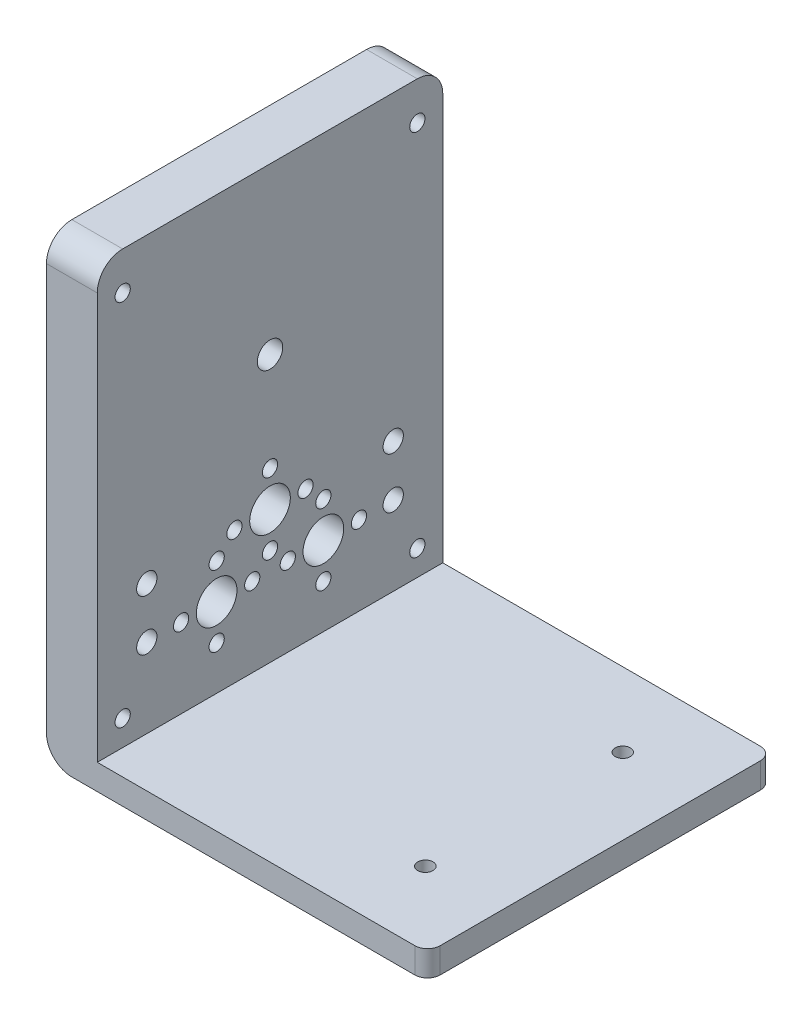
from build123d import *

# Parameters (mm, degrees)
EXTRUDE_1_DEPTH     = 68
SKETCH_2_R          = 2.5
CUT_EXTRUDE_1_DEPTH = 76
FILLET_1_R          = 5
FILLET_3_R          = 5
SKETCH_7_R          = 1.5
CUT_EXTRUDE_5_DEPTH = 10
SKETCH_8_R          = 1.5
CUT_EXTRUDE_6_DEPTH = 10
SKETCH_9_R          = 1.5
CUT_EXTRUDE_7_DEPTH = 10
FILLET_4_R          = 2.5
SKETCH_14_R         = 2
SKETCH_14_R_2       = 1.5
SKETCH_14_R_3       = 4
CUT_EXTRUDE_9_DEPTH = 76


with BuildPart() as part:
    # 草图1 → 凸台-拉伸1 (new body)
    with BuildSketch(Plane.XY):
        Polygon((-15.418994413, 41.899441341), (-15.418994413, -48.100558659), (59.581005587, -48.100558659), (59.581005587, -43.100558659), (-5.418994413, -43.100558659), (-5.418994413, 41.899441341), align=None)
    extrude(amount=EXTRUDE_1_DEPTH)

    # 草图2 → 切除-拉伸1 (cut, through all)
    with BuildSketch(Plane.ZY.offset(15.418994413)):
        with Locations((34, 9.399441341)):
            Circle(SKETCH_2_R)
    extrude(amount=-CUT_EXTRUDE_1_DEPTH, mode=Mode.SUBTRACT)

    # 圆角1
    fillet_1_edges = [part.edges().sort_by_distance(p)[0] for p in [
        (-10.418994413, 41.899441341, 68),
        (-10.418994413, 41.899441341, 0),
    ]]
    fillet(fillet_1_edges, radius=FILLET_1_R)

    # 圆角3
    fillet_3_edges = [part.edges().sort_by_distance(p)[0] for p in [
        (-15.418994413, -48.100558659, 34),
    ]]
    fillet(fillet_3_edges, radius=FILLET_3_R)

    # 草图7 → 切除-拉伸5 (cut)
    with BuildSketch(Plane.ZY.offset(15.418994413)):
        with Locations((63, 34.399441341)):
            Circle(SKETCH_7_R)
        with Locations((5, 34.399441341)):
            Circle(SKETCH_7_R)
    extrude(amount=-CUT_EXTRUDE_5_DEPTH, mode=Mode.SUBTRACT)

    # 草图8 → 切除-拉伸6 (cut)
    with BuildSketch(Plane.XZ.offset(48.100558659)):
        with Locations((44.581005587, 14.571428571)):
            Circle(SKETCH_8_R)
        with Locations((44.581005587, 53.428571429)):
            Circle(SKETCH_8_R)
    extrude(amount=-CUT_EXTRUDE_6_DEPTH, mode=Mode.SUBTRACT)

    # 草图9 → 切除-拉伸7 (cut)
    with BuildSketch(Plane.ZY.offset(15.418994413)):
        with Locations((5, -38.100558659)):
            Circle(SKETCH_9_R)
        with Locations((63, -38.100558659)):
            Circle(SKETCH_9_R)
    extrude(amount=-CUT_EXTRUDE_7_DEPTH, mode=Mode.SUBTRACT)

    # 圆角4
    fillet_4_edges = [part.edges().sort_by_distance(p)[0] for p in [
        (59.581005587, -45.600558659, 68),
        (59.581005587, -45.600558659, 0),
    ]]
    fillet(fillet_4_edges, radius=FILLET_4_R)

    # 草图14 → 切除-拉伸9 (cut, through all)
    with BuildSketch(Plane.ZY.offset(15.418994413)):
        with Locations((58.25, -27.496370313)):
            Circle(SKETCH_14_R)
        with Locations((58.25, -17.496370313)):
            Circle(SKETCH_14_R)
        with Locations((9.75, -17.496370313)):
            Circle(SKETCH_14_R)
        with Locations((9.75, -27.496370313)):
            Circle(SKETCH_14_R)
        with Locations((23.5, -34.496370313)):
            Circle(SKETCH_14_R_2)
        with Locations((44.5, -27.496370313)):
            Circle(SKETCH_14_R_3)
        with Locations((23.5, -27.496370313)):
            Circle(SKETCH_14_R_3)
        with Locations((34, -16.996370313)):
            Circle(SKETCH_14_R_3)
        with Locations((44.5, -20.496370313)):
            Circle(SKETCH_14_R_2)
        with Locations((51.5, -27.496370313)):
            Circle(SKETCH_14_R_2)
        with Locations((44.5, -34.496370313)):
            Circle(SKETCH_14_R_2)
        with Locations((16.5, -27.496370313)):
            Circle(SKETCH_14_R_2)
        with Locations((23.5, -20.496370313)):
            Circle(SKETCH_14_R_2)
        with Locations((30.5, -27.496370313)):
            Circle(SKETCH_14_R_2)
        with Locations((27, -16.996370313)):
            Circle(SKETCH_14_R_2)
        with Locations((34, -9.996370313)):
            Circle(SKETCH_14_R_2)
        with Locations((41, -16.996370313)):
            Circle(SKETCH_14_R_2)
        with Locations((34, -23.996370313)):
            Circle(SKETCH_14_R_2)
        with Locations((37.5, -27.496370313)):
            Circle(SKETCH_14_R_2)
    extrude(amount=-CUT_EXTRUDE_9_DEPTH, mode=Mode.SUBTRACT)


solid = part.part
